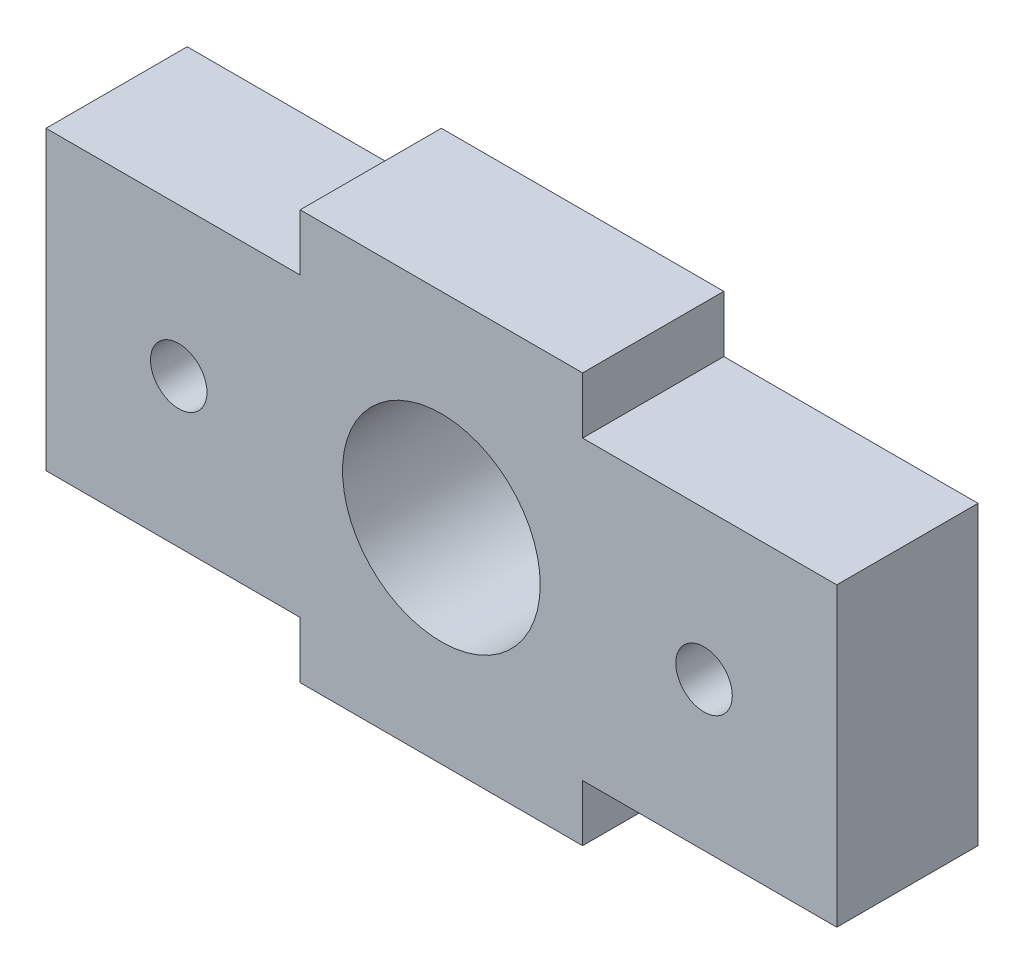
from build123d import *

# Parameters (mm, degrees)
SKETCH1_W           = 28
SKETCH1_H           = 10.5
SKETCH1_R           = 3.5
SKETCH1_R_2         = 1
SKETCH1_W_2         = 10
SKETCH1_H_2         = 2
BOSS_EXTRUDE1_DEPTH = 5


with BuildPart() as part:
    # Sketch1 → Boss-Extrude1 (new body)
    with BuildSketch(Plane.XY):
        Rectangle(SKETCH1_W, SKETCH1_H)
        Circle(SKETCH1_R, mode=Mode.SUBTRACT)
        with Locations((9.3, 0)):
            Circle(SKETCH1_R_2, mode=Mode.SUBTRACT)
        with Locations((-9.3, 0)):
            Circle(SKETCH1_R_2, mode=Mode.SUBTRACT)
        with Locations((0, 6.25)):
            Rectangle(SKETCH1_W_2, SKETCH1_H_2)
        with Locations((0, -6.25)):
            Rectangle(SKETCH1_W_2, SKETCH1_H_2)
    extrude(amount=BOSS_EXTRUDE1_DEPTH)


solid = part.part
